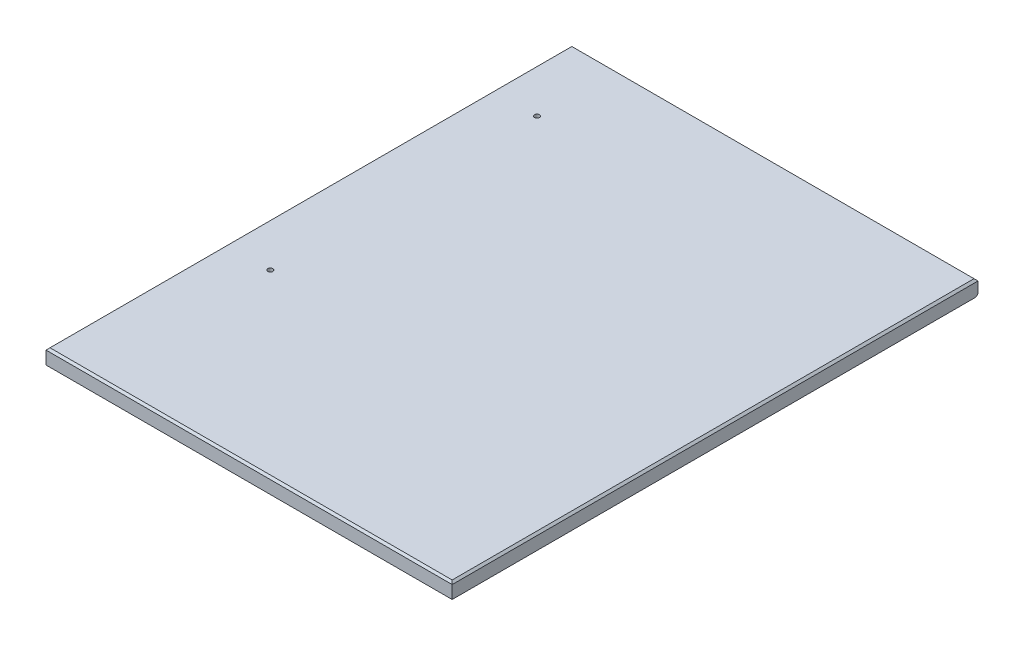
from build123d import *

# Parameters (mm, degrees)
SKETCH1_W           = 517.4488
SKETCH1_H           = 669.925
BOSS_EXTRUDE1_DEPTH = 19.05
CHAMFER1_SIZE       = 2.54
CHAMFER2_SIZE       = 2.54
SKETCH2_R           = 3.175
CUT_EXTRUDE1_DEPTH  = 20.05


with BuildPart() as part:
    # Sketch1 → Boss-Extrude1 (new body)
    with BuildSketch(Plane(origin=(0, 0, 0), x_dir=(1, 0, 0), z_dir=(0, 1, 0))):
        with Locations((258.7244, 334.9625)):
            Rectangle(SKETCH1_W, SKETCH1_H)
    extrude(amount=BOSS_EXTRUDE1_DEPTH)

    # Chamfer1
    chamfer1_edges = [part.edges().sort_by_distance(p)[0] for p in [
        (517.4488, 19.05, -334.9625),
        (258.7244, 19.05, -669.925),
        (0, 19.05, -334.9625),
        (258.7244, 19.05, 0),
    ]]
    chamfer(chamfer1_edges, length=CHAMFER1_SIZE)

    # Chamfer2
    chamfer2_edges = [part.edges().sort_by_distance(p)[0] for p in [
        (258.7244, 0, -669.925),
    ]]
    chamfer(chamfer2_edges, length=CHAMFER2_SIZE)

    # Sketch2 → Cut-Extrude1 (cut, through all)
    with BuildSketch(Plane(origin=(0, 19.05, 0), x_dir=(1, 0, 0), z_dir=(0, 1, 0))):
        with Locations((57.15, 568.325)):
            Circle(SKETCH2_R)
        with Locations((57.15, 228.6)):
            Circle(SKETCH2_R)
        with Locations((666.75, 568.325)):
            Circle(SKETCH2_R)
        with Locations((666.75, 228.6)):
            Circle(SKETCH2_R)
    extrude(amount=-CUT_EXTRUDE1_DEPTH, mode=Mode.SUBTRACT)


solid = part.part
